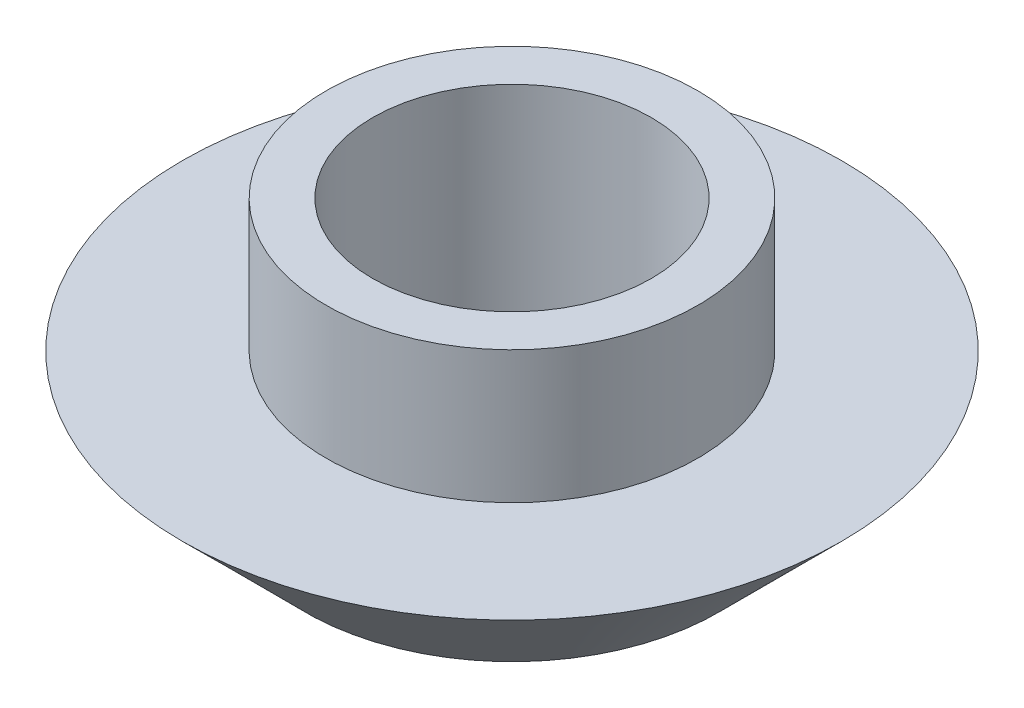
from build123d import *

# Parameters (mm, degrees)
OTWORY_USTALAJ_CE_6_0MM1_D = 6


with BuildPart() as part:
    # Szkic1 → Obrót1 (revolve)
    with BuildSketch(Plane.XY):
        Polygon((0, 0), (0, 5.495), (4, 5.495), (4, 2.645), (7.095, 2.645), (4.45, 0), align=None)
    revolve(axis=Axis((0, 0, 0), (0, 1, 0)))

    # Otwory ustalające Ø6.0mm1 (through all)
    with Locations(Plane(origin=(0, 5.495, 0), x_dir=(1, 0, 0), z_dir=(0, 1, 0))):
        with Locations((0, 0)):
            Hole(OTWORY_USTALAJ_CE_6_0MM1_D / 2)


solid = part.part
